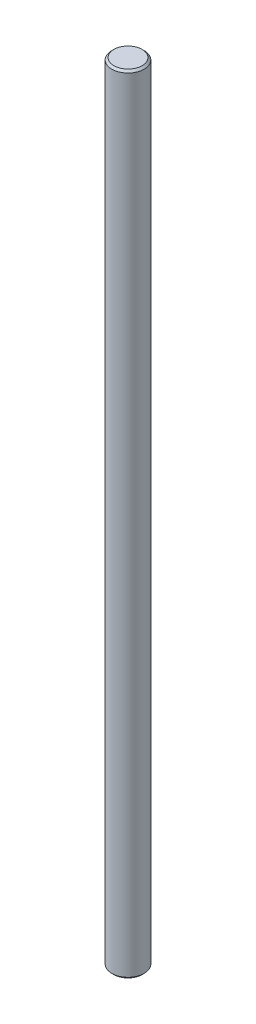
from build123d import *

# Parameters (mm, degrees)
SKETCH1_R           = 4
BOSS_EXTRUDE1_DEPTH = 97.5
CHAMFER1_SIZE       = 0.5


with BuildPart() as part:
    # Sketch1 → Boss-Extrude1 (new body, symmetric)
    with BuildSketch(Plane(origin=(0, 0, 0), x_dir=(1, 0, 0), z_dir=(0, 1, 0))):
        Circle(SKETCH1_R)
    extrude(amount=BOSS_EXTRUDE1_DEPTH, both=True)

    # Chamfer1
    chamfer1_edges = [part.edges().sort_by_distance(p)[0] for p in [
        (-4, -97.5, 0),
        (-4, 97.5, 0),
    ]]
    chamfer(chamfer1_edges, length=CHAMFER1_SIZE)


solid = part.part
